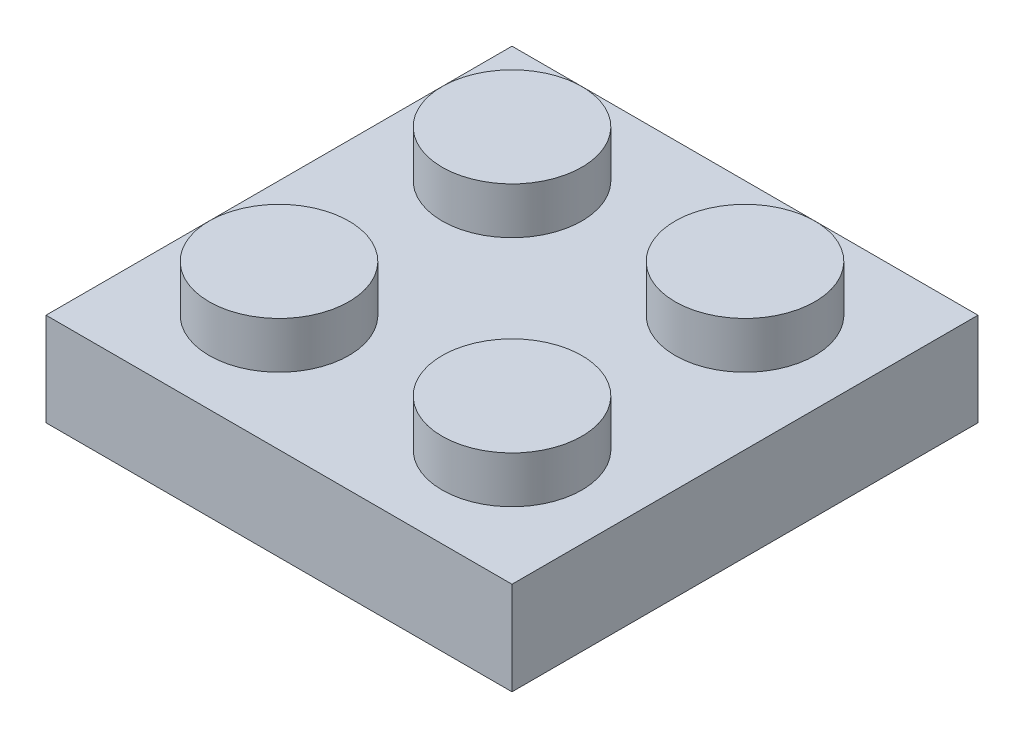
from build123d import *

# Parameters (mm, degrees)
SKETCH1_W           = 10
SKETCH1_H           = 10
BOSS_EXTRUDE1_DEPTH = 1
SKETCH1_4_W         = 10
SKETCH1_4_H         = 10
SKETCH1_4_W_2       = 8
SKETCH1_4_H_2       = 8
SKETCH1_4_R         = 2.035533906
SKETCH1_4_R_2       = 1.5
BOSS_EXTRUDE3_DEPTH = 1
SKETCH2_R           = 1.5
BOSS_EXTRUDE4_DEPTH = 1


with BuildPart() as part:
    # Sketch1 → Boss-Extrude1 (new body)
    with BuildSketch(Plane(origin=(0, 0, 0), x_dir=(1, 0, 0), z_dir=(0, 1, 0))):
        with Locations((5, 5)):
            Rectangle(SKETCH1_W, SKETCH1_H)
    extrude(amount=BOSS_EXTRUDE1_DEPTH)

    # Sketch1_4 → Boss-Extrude3 (add)
    # profile 1 of 2: a face of its own
    with BuildSketch(Plane(origin=(0, 0, 0), x_dir=(1, 0, 0), z_dir=(0, 1, 0))):
        with Locations((5, 5)):
            Rectangle(SKETCH1_4_W, SKETCH1_4_H)
        with Locations((5, 5)):
            Rectangle(SKETCH1_4_W_2, SKETCH1_4_H_2, mode=Mode.SUBTRACT)
    # profile 2 of 2: a face of its own
    with BuildSketch(Plane(origin=(0, 0, 0), x_dir=(1, 0, 0), z_dir=(0, 1, 0))):
        with Locations((5, 5)):
            Circle(SKETCH1_4_R)
        with Locations((5, 5)):
            Circle(SKETCH1_4_R_2, mode=Mode.SUBTRACT)
    extrude(amount=-BOSS_EXTRUDE3_DEPTH)

    # Sketch2 → Boss-Extrude4 (add)
    with BuildSketch(Plane(origin=(0, 1, 0), x_dir=(1, 0, 0), z_dir=(0, 1, 0))):
        with Locations((7.5, 2.5)):
            Circle(SKETCH2_R)
        with Locations((2.5, 2.5)):
            Circle(SKETCH2_R)
        with Locations((2.5, 7.5)):
            Circle(SKETCH2_R)
        with Locations((7.5, 7.5)):
            Circle(SKETCH2_R)
    extrude(amount=BOSS_EXTRUDE4_DEPTH)


solid = part.part
